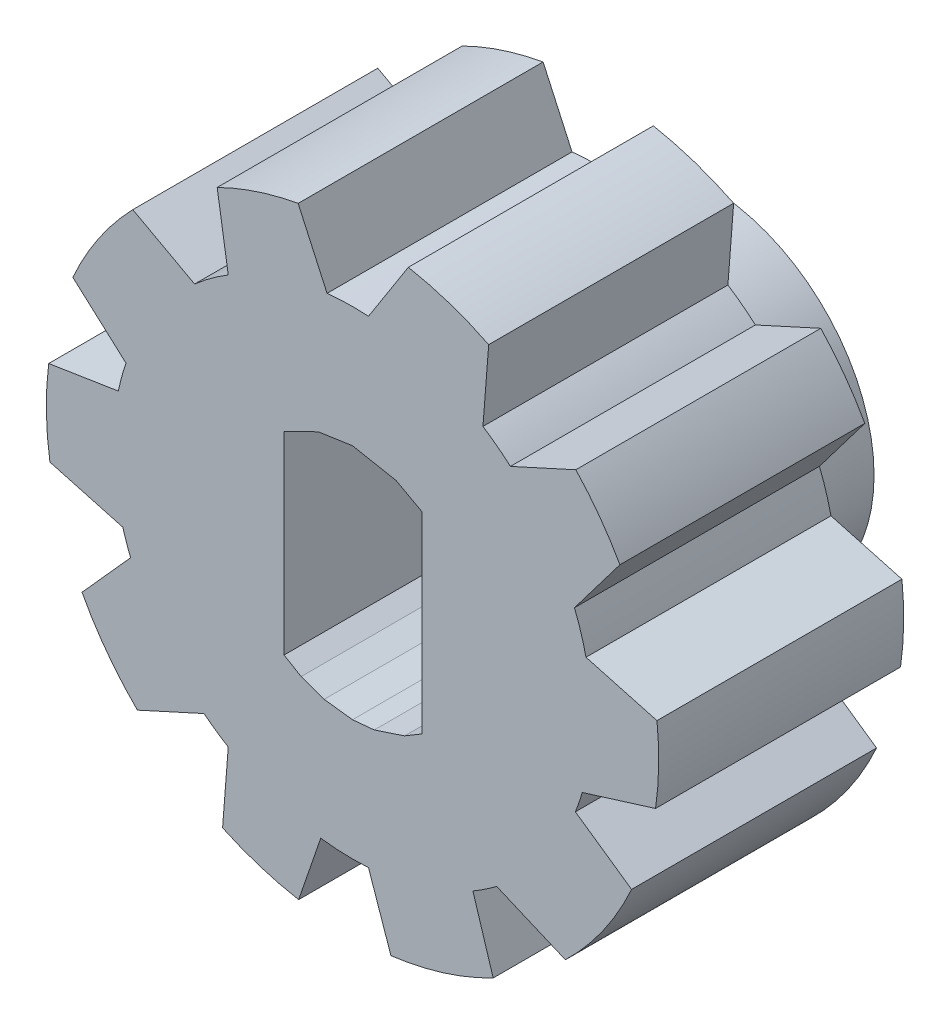
from build123d import *

# Parameters (mm, degrees)
SKETCH1_R           = 6.35
BOSS_EXTRUDE1_DEPTH = 5.08
SKETCH2_R           = 0.804650072
CUT_EXTRUDE1_DEPTH  = 5.08
CUT_EXTRUDE4_DEPTH  = 5.08
SKETCH7_R           = 3.476857069
BOSS_EXTRUDE3_DEPTH = 2.258601292
SKETCH10_R          = 0.804650072
CUT_EXTRUDE5_DEPTH  = 5.12259779
SKETCH11_R          = 0.474817283
CUT_EXTRUDE6_DEPTH  = 9.144


with BuildPart() as part:
    # Sketch1 → Boss-Extrude1 (new body)
    with BuildSketch(Plane.XY):
        Circle(SKETCH1_R)
    extrude(amount=BOSS_EXTRUDE1_DEPTH)

    # Sketch2 → Cut-Extrude1 (cut)
    with BuildSketch(Plane.XY.offset(5.08)):
        Circle(SKETCH2_R)
    extrude(amount=-CUT_EXTRUDE1_DEPTH, mode=Mode.SUBTRACT)

    # Sketch6 → Cut-Extrude4 (cut)
    with BuildSketch(Plane(origin=(0, 0, 0), x_dir=(-1, 0, 0), z_dir=(0, 0, -1))):
        with BuildLine():
            Line((-6.313419859, 0.680609785), (-4.841727293, 1.082552663))
            ThreePointArc((-4.841727293, 1.082552663), (-4.737782551, 1.472297507), (-4.602520026, 1.852310143))
            Line((-4.602520026, 1.852310143), (-5.544711841, 3.094942746))
            ThreePointArc((-5.544711841, 3.094942746), (-6.050708452, 1.926506484), (-6.313419859, 0.680609785))
        make_face()
        with BuildLine():
            ThreePointArc((-4.621895526, -1.803420416), (-4.697643554, -1.595740734), (-4.764064977, -1.384892901))
            Line((-4.764064977, -1.384892901), (-6.284089397, -0.912535181))
            ThreePointArc((-6.284089397, -0.912535181), (-6.095179755, -1.780809857), (-5.786915427, -2.614213043))
            Line((-5.786915427, -2.614213043), (-4.621895526, -1.803420416))
        make_face()
        with BuildLine():
            ThreePointArc((-2.49633596, -4.287487636), (-2.747933203, -4.130751331), (-2.989720929, -3.959269152))
            Line((-2.989720929, -3.959269152), (-4.414172057, -4.564820375))
            ThreePointArc((-4.414172057, -4.564820375), (-3.704724213, -5.157278207), (-2.916783485, -5.640467543))
            Line((-2.916783485, -5.640467543), (-2.49633596, -4.287487636))
        make_face()
        with BuildLine():
            ThreePointArc((0.658971441, -4.91731635), (0.164985262, -4.958530358), (-0.330647946, -4.950243972))
            Line((-0.330647946, -4.950243972), (-0.797062617, -6.299777074))
            ThreePointArc((-0.797062617, -6.299777074), (0.162157154, -6.347929194), (1.117667403, -6.250865506))
            Line((1.117667403, -6.250865506), (0.658971441, -4.91731635))
        make_face()
        with BuildLine():
            ThreePointArc((3.079848524, -3.889572794), (2.834017843, -4.072172186), (2.577390132, -4.23925743))
            Line((2.577390132, -4.23925743), (2.695058949, -5.74970932))
            ThreePointArc((2.695058949, -5.74970932), (3.630700167, -5.209656063), (4.461255519, -4.518816127))
            Line((4.461255519, -4.518816127), (3.079848524, -3.889572794))
        make_face()
        with BuildLine():
            ThreePointArc((4.764064977, -1.384892901), (4.689120213, -1.620615648), (4.602520026, -1.852310143))
            Line((4.602520026, -1.852310143), (5.609586886, -2.975741079))
            ThreePointArc((5.609586886, -2.975741079), (6.026210342, -2.001821398), (6.2751364, -0.972195025))
            Line((6.2751364, -0.972195025), (4.764064977, -1.384892901))
        make_face()
        with BuildLine():
            ThreePointArc((4.697742855, 1.595448377), (4.785985372, 1.307129477), (4.856550498, 1.013982598))
            Line((4.856550498, 1.013982598), (6.301072583, 0.786755552))
            ThreePointArc((6.301072583, 0.786755552), (6.117140529, 1.703846165), (5.800483524, 2.583968051))
            Line((5.800483524, 2.583968051), (4.697742855, 1.595448377))
        make_face()
        with BuildLine():
            Line((-4.631054346, 4.34463297), (-3.274854363, 3.726871658))
            ThreePointArc((-3.274854363, 3.726871658), (-2.997527533, 3.953362131), (-2.704587495, 4.159260744))
            Line((-2.704587495, 4.159260744), (-2.823654461, 5.68765993))
            ThreePointArc((-2.823654461, 5.68765993), (-3.787360718, 5.096900901), (-4.631054346, 4.34463297))
        make_face()
        with BuildLine():
            Line((-1.15729269, 6.243650665), (-0.330647946, 4.950243972))
            ThreePointArc((-0.330647946, 4.950243972), (0.099169547, 4.960283142), (0.528242314, 4.933072421))
            Line((0.528242314, 4.933072421), (1.127688946, 6.249065341))
            ThreePointArc((1.127688946, 6.249065341), (-0.015047428, 6.349982171), (-1.15729269, 6.243650665))
        make_face()
        with BuildLine():
            Line((2.80655769, 5.696115688), (2.577390132, 4.23925743))
            ThreePointArc((2.577390132, 4.23925743), (2.937316156, 3.998301796), (3.274854363, 3.726871658))
            Line((3.274854363, 3.726871658), (4.557114361, 4.422127169))
            ThreePointArc((4.557114361, 4.422127169), (3.736532912, 5.134279092), (2.80655769, 5.696115688))
        make_face()
    extrude(amount=-CUT_EXTRUDE4_DEPTH, mode=Mode.SUBTRACT)

    # Sketch7 → Boss-Extrude3 (add)
    with BuildSketch(Plane(origin=(0, 0, 0), x_dir=(-1, 0, 0), z_dir=(0, 0, -1))):
        Circle(SKETCH7_R)
    extrude(amount=BOSS_EXTRUDE3_DEPTH)

    # Sketch10 → Cut-Extrude5 (cut)
    with BuildSketch(Plane.XY.offset(5.08)):
        Circle(SKETCH10_R)
        Polygon((1.437219643, 0), (1.437219643, -1.996796237), (1.079397463, -2.210813568), (0.451137939, -2.418526426), (0, -2.460242979), (-0.588709584, -2.388768834), (-1.06538084, -2.217602124), (-1.420507786, -2.008719279), (-1.420507786, 0), (0, 0), align=None)
        with BuildLine():
            Line((-0.804650072, 0), (0, 0))
            Line((0, 0), (0.804650072, 0))
            ThreePointArc((0.804650072, 0), (0, 0.804650072), (-0.804650072, 0))
        make_face()
        with BuildLine():
            Line((0.804650072, 0), (0, 0))
            Line((0, 0), (-0.804650072, 0))
            ThreePointArc((-0.804650072, 0), (0, -0.804650072), (0.804650072, 0))
        make_face()
        Polygon((1.437219643, 1.996796237), (1.437219643, 0), (0, 0), (-1.420507786, 0), (-1.420507786, 2.008719279), (-0.710253893, 2.355490378), (0, 2.460242979), (0.902275879, 2.288819292), align=None)
    extrude(amount=-CUT_EXTRUDE5_DEPTH, mode=Mode.SUBTRACT)

    # Sketch11 → Cut-Extrude6 (cut)
    with BuildSketch(Plane(origin=(0, 0, -2.258601292), x_dir=(-1, 0, 0), z_dir=(0, 0, -1))):
        Circle(SKETCH11_R)
    extrude(amount=-CUT_EXTRUDE6_DEPTH, mode=Mode.SUBTRACT)


solid = part.part
